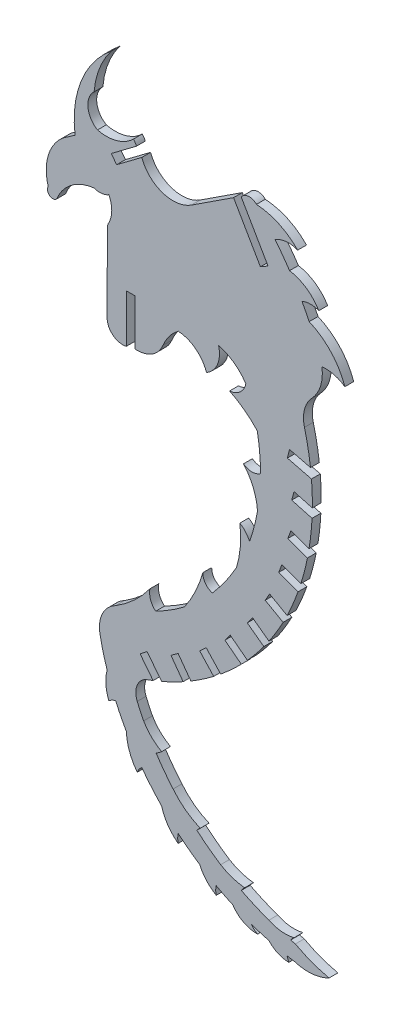
from build123d import *

# Parameters (mm, degrees)
BOSS_EXTRUDE1_DEPTH = 1.524


with BuildPart() as part:
    # Sketch1 → Boss-Extrude1 (new body)
    with BuildSketch(Plane.XY):
        with BuildLine():
            Line((-19.602484905, -30.40458867), (-17.182373841, -33.018427625))
            ThreePointArc((-17.182373841, -33.018427625), (-19.114471728, -34.403412724), (-21.120030481, -35.679704249))
            Line((-21.120030481, -35.679704249), (-23.318089916, -32.655808204))
            Line((-23.318089916, -32.655808204), (-24.551989159, -33.552918309))
            Line((-24.551989159, -33.552918309), (-22.451777673, -36.443937506))
            ThreePointArc((-22.451777673, -36.443937506), (-24.287296841, -37.398597732), (-26.166537799, -38.264022589))
            Line((-26.166537799, -38.264022589), (-28.67690709, -35.050088475))
            Line((-28.67690709, -35.050088475), (-29.879014549, -35.989918424))
            Line((-29.879014549, -35.989918424), (-27.633755498, -38.866035398))
            Line((-27.633755498, -38.866035398), (-28.929944275, -39.345306926))
            ThreePointArc((-28.929944275, -39.345306926), (-30.438413926, -41.060914268), (-30.37611387, -43.344531561))
            ThreePointArc((-30.37611387, -43.344531561), (-29.844797236, -44.539156878), (-29.273288892, -45.715084268))
            ThreePointArc((-29.273288892, -45.715084268), (-27.924618868, -47.442888916), (-26.166537799, -48.751846781))
            ThreePointArc((-26.166537799, -48.751846781), (-26.620268309, -49.124877395), (-27.129745176, -49.417206895))
            ThreePointArc((-27.129745176, -49.417206895), (-25.71988883, -51.425193975), (-24.185195687, -53.3394625))
            ThreePointArc((-24.185195687, -53.3394625), (-22.06528685, -55.395285651), (-19.507611608, -56.871334316))
            ThreePointArc((-19.507611608, -56.871334316), (-19.825662265, -57.136301645), (-20.087445304, -57.456978345))
            ThreePointArc((-20.087445304, -57.456978345), (-18.085947134, -59.072396881), (-15.98121565, -60.550800532))
            ThreePointArc((-15.98121565, -60.550800532), (-13.992971134, -61.479327702), (-11.846399806, -61.934860906))
            ThreePointArc((-11.846399806, -61.934860906), (-12.152170676, -62.259895124), (-12.422100483, -62.615255459))
            ThreePointArc((-12.422100483, -62.615255459), (-10.068181572, -63.719208102), (-7.645225941, -64.662039844))
            ThreePointArc((-7.645225941, -64.662039844), (-5.524325064, -65.2816944), (-3.319391114, -65.138660927))
            ThreePointArc((-3.319391114, -65.138660927), (-3.627748979, -65.435576398), (-3.899262019, -65.766520562))
            ThreePointArc((-3.899262019, -65.766520562), (-3.498948493, -65.860560168), (-3.097654962, -65.950325804))
            ThreePointArc((-3.097654962, -65.950325804), (-0.262873804, -67.244935383), (2.725203814, -68.130028787))
            ThreePointArc((2.725203814, -68.130028787), (-0.223324125, -68.977009903), (-3.2727907, -68.64242415))
            ThreePointArc((-3.2727907, -68.64242415), (-3.894035953, -68.5438652), (-4.513665711, -68.435613212))
            ThreePointArc((-4.513665711, -68.435613212), (-4.38771046, -68.856992068), (-4.205892413, -69.257450634))
            ThreePointArc((-4.205892413, -69.257450634), (-6.086864066, -68.859330249), (-7.645225834, -67.733247303))
            ThreePointArc((-7.645225834, -67.733247303), (-9.178691286, -67.291765398), (-10.693458736, -66.789866862))
            ThreePointArc((-10.693458736, -66.789866862), (-10.204080859, -67.331503597), (-9.59460317, -67.733247303))
            ThreePointArc((-9.59460317, -67.733247303), (-12.022729115, -67.178660923), (-13.872943452, -65.511307163))
            ThreePointArc((-13.872943452, -65.511307163), (-15.32207287, -64.820487366), (-16.742511873, -64.072449199))
            ThreePointArc((-16.742511873, -64.072449199), (-16.83298224, -64.791878181), (-16.742511873, -65.511307163))
            ThreePointArc((-16.742511873, -65.511307163), (-18.424401454, -64.14926984), (-19.602484905, -62.333776074))
            ThreePointArc((-19.602484905, -62.333776074), (-21.500743497, -60.988003895), (-23.318089916, -59.534821033))
            ThreePointArc((-23.318089916, -59.534821033), (-23.391769725, -60.287774776), (-23.318089916, -61.040728518))
            ThreePointArc((-23.318089916, -61.040728518), (-25.083741377, -59.189287964), (-26.166537799, -56.871334316))
            ThreePointArc((-26.166537799, -56.871334316), (-27.943176775, -54.916527573), (-29.587813978, -52.849432044))
            ThreePointArc((-29.587813978, -52.849432044), (-30.057930826, -53.336751691), (-30.37611387, -53.934455497))
            ThreePointArc((-30.37611387, -53.934455497), (-31.72023181, -51.488991265), (-32.263360174, -48.751846781))
            ThreePointArc((-32.263360174, -48.751846781), (-33.224295897, -46.960630757), (-34.093606765, -45.123200235))
            ThreePointArc((-34.093606765, -45.123200235), (-34.724295301, -45.333332251), (-35.26852772, -45.715084222))
            ThreePointArc((-35.26852772, -45.715084222), (-35.778431287, -43.508727905), (-35.573142184, -41.253541387))
            ThreePointArc((-35.573142184, -41.253541387), (-36.262207071, -38.884767803), (-36.804911157, -36.478241055))
            ThreePointArc((-36.804911157, -36.478241055), (-36.379187413, -33.235780646), (-34.093606765, -30.896782716))
            ThreePointArc((-34.093606765, -30.896782716), (-30.873720288, -28.447609442), (-28.183432172, -25.426273891))
            ThreePointArc((-28.183432172, -25.426273891), (-28.077817746, -26.989377804), (-27.18485716, -28.276649974))
            ThreePointArc((-27.18485716, -28.276649974), (-24.632848641, -26.822449292), (-22.219060199, -25.148808811))
            ThreePointArc((-22.219060199, -25.148808811), (-20.352965662, -21.922026938), (-19.043157097, -18.432208663))
            ThreePointArc((-19.043157097, -18.432208663), (-18.616398021, -19.838562637), (-17.400633216, -20.664317292))
            ThreePointArc((-17.400633216, -20.664317292), (-15.156999182, -17.818891426), (-13.236154755, -14.746319421))
            ThreePointArc((-13.236154755, -14.746319421), (-12.586187947, -11.330292244), (-12.664655577, -7.853865722))
            ThreePointArc((-12.664655577, -7.853865722), (-11.678390517, -8.675882943), (-10.999550853, -9.765657136))
            ThreePointArc((-10.999550853, -9.765657136), (-10.205411538, -7.19334204), (-9.621867643, -4.5652365))
            ThreePointArc((-9.621867643, -4.5652365), (-10.343001299, -1.421301186), (-12.033673017, 1.325695747))
            ThreePointArc((-12.033673017, 1.325695747), (-10.564897836, 0.839133584), (-9.096122655, 1.325695747))
            ThreePointArc((-9.096122655, 1.325695747), (-9.238337065, 4.398439349), (-9.663764364, 7.444911045))
            ThreePointArc((-9.663764364, 7.444911045), (-11.889027046, 9.445126668), (-14.439462627, 11.009714438))
            ThreePointArc((-14.439462627, 11.009714438), (-12.622320549, 11.776198112), (-11.639197468, 13.485868127))
            ThreePointArc((-11.639197468, 13.485868127), (-13.679495335, 15.613321564), (-16.345152823, 16.871551933))
            ThreePointArc((-16.345152823, 16.871551933), (-16.5083071, 13.966949207), (-18.41834042, 11.772613536))
            ThreePointArc((-18.41834042, 11.772613536), (-20.293185379, 14.376897698), (-23.294559088, 15.512281101))
            ThreePointArc((-23.294559088, 15.512281101), (-24.845480977, 13.979745117), (-25.932343938, 12.089572069))
            ThreePointArc((-25.932343938, 12.089572069), (-27.851371701, 9.818950969), (-30.7393246, 9.113177784))
            Line((-30.7393246, 9.113177784), (-30.739365801, 17.063759068))
            Line((-30.739365801, 17.063759068), (-32.263360174, 17.063759068))
            Line((-32.263360174, 17.063759068), (-32.263360174, 8.761268716))
            ThreePointArc((-32.263360174, 8.761268716), (-34.555343687, 9.269109006), (-35.573142184, 11.38457028))
            Line((-35.573142184, 11.38457028), (-35.527926853, 24.762214687))
            ThreePointArc((-35.527926853, 24.762214687), (-35.463572652, 25.273102917), (-35.26852772, 25.749659021))
            ThreePointArc((-35.26852772, 25.749659021), (-34.76819854, 27.834378756), (-35.26852772, 29.919098491))
            ThreePointArc((-35.26852772, 29.919098491), (-36.512710954, 29.485955181), (-37.820754807, 29.642882946))
            ThreePointArc((-37.820754807, 29.642882946), (-41.729979288, 28.095226002), (-44.292851433, 24.762214687))
            ThreePointArc((-44.292851433, 24.762214687), (-45.513428247, 24.680938121), (-45.729232446, 25.88503205))
            ThreePointArc((-45.729232446, 25.88503205), (-45.746623729, 30.530821656), (-43.205439397, 34.420043392))
            Line((-43.205439397, 34.420043392), (-41.098071776, 35.89971711))
            ThreePointArc((-41.098071776, 35.89971711), (-40.031539596, 44.562472245), (-34.850374923, 51.586456159))
            ThreePointArc((-34.850374923, 51.586456159), (-36.889272039, 48.013666537), (-37.820754807, 44.006888906))
            ThreePointArc((-37.820754807, 44.006888906), (-38.876801563, 41.163061153), (-37.234707854, 38.612351586))
            ThreePointArc((-37.234707854, 38.612351586), (-33.903641276, 38.676673562), (-31.024602142, 40.353359439))
            ThreePointArc((-31.024602142, 40.353359439), (-30.727463579, 39.97593433), (-30.50730984, 39.548999474))
            Line((-30.50730984, 39.548999474), (-34.850374923, 36.287545289))
            Line((-34.850374923, 36.287545289), (-33.934388939, 35.066561951))
            Line((-33.934388939, 35.066561951), (-29.590906246, 38.32814788))
            ThreePointArc((-29.590906246, 38.32814788), (-26.00393842, 34.837993903), (-21.040361546, 35.478632319))
            Line((-21.040361546, 35.478632319), (-13.754877133, 40.23562438))
            Line((-13.754877133, 40.23562438), (-9.121298801, 32.225216494))
            Line((-9.121298801, 32.225216494), (-7.801960889, 32.988207094))
            Line((-7.801960889, 32.988207094), (-12.433552393, 40.99861498))
            ThreePointArc((-12.433552393, 40.99861498), (-11.167432629, 41.720791341), (-9.802955112, 41.208152036))
            ThreePointArc((-9.802955112, 41.208152036), (-5.936656137, 40.237500091), (-2.694493928, 37.918272381))
            ThreePointArc((-2.694493928, 37.918272381), (-4.677929815, 38.219090922), (-6.566708996, 37.543056222))
            ThreePointArc((-6.566708996, 37.543056222), (-5.293674604, 35.8778749), (-4.09231636, 34.160265))
            ThreePointArc((-4.09231636, 34.160265), (-1.184466943, 32.989300759), (0.952741463, 30.696031101))
            ThreePointArc((0.952741463, 30.696031101), (-0.50482345, 30.961916762), (-1.954175494, 30.654395527))
            ThreePointArc((-1.954175494, 30.654395527), (-1.31039762, 29.454297412), (-0.699896059, 28.236934163))
            ThreePointArc((-0.699896059, 28.236934163), (3.077515896, 25.562161313), (5.454065658, 21.590352895))
            ThreePointArc((5.454065658, 21.590352895), (3.561132414, 22.456260476), (1.484832877, 22.604491527))
            ThreePointArc((1.484832877, 22.604491527), (1.262062582, 19.608548163), (-0.248272055, 17.011589841))
            ThreePointArc((-0.248272055, 17.011589841), (-1.52399282, 14.685708096), (-1.521843248, 12.032938837))
            ThreePointArc((-1.521843248, 12.032938837), (-0.911505152, 9.300940608), (-0.479904302, 6.535068661))
            Line((-0.479904302, 6.535068661), (-4.09231636, 7.444911045))
            Line((-4.09231636, 7.444911045), (-4.463877014, 5.965623344))
            Line((-4.463877014, 5.965623344), (-0.311141971, 4.919492018))
            ThreePointArc((-0.311141971, 4.919492018), (-0.184664396, 2.793264076), (-0.16344276, 0.663383449))
            Line((-0.16344276, 0.663383449), (-3.319391114, 1.52776024))
            Line((-3.319391114, 1.52776024), (-3.722743043, 0.055426943))
            Line((-3.722743043, 0.055426943), (-0.21378081, -0.904272298))
            ThreePointArc((-0.21378081, -0.904272298), (-0.404871254, -3.314288011), (-0.730863609, -5.709788017))
            Line((-0.730863609, -5.709788017), (-3.855869134, -4.5652365))
            Line((-3.855869134, -4.5652365), (-4.380425171, -5.998824116))
            Line((-4.380425171, -5.998824116), (-1.008562685, -7.233716773))
            ThreePointArc((-1.008562685, -7.233716773), (-1.519379645, -9.456694672), (-2.147145073, -11.649518258))
            Line((-2.147145073, -11.649518258), (-5.415628436, -10.427745988))
            Line((-5.415628436, -10.427745988), (-5.952105948, -11.856366535))
            Line((-5.952105948, -11.856366535), (-2.631905046, -13.09920701))
            ThreePointArc((-2.631905046, -13.09920701), (-3.509357984, -15.369765227), (-4.513665711, -17.587133997))
            Line((-4.513665711, -17.587133997), (-7.533721879, -15.867034763))
            Line((-7.533721879, -15.867034763), (-8.28876466, -17.19332708))
            Line((-8.28876466, -17.19332708), (-5.206998321, -18.946814274))
            ThreePointArc((-5.206998321, -18.946814274), (-6.370880972, -20.997449379), (-7.645225834, -22.981327484))
            Line((-7.645225834, -22.981327484), (-10.482362635, -20.895023282))
            Line((-10.482362635, -20.895023282), (-11.388413973, -22.123954946))
            Line((-11.388413973, -22.123954946), (-8.527199223, -24.229133501))
            ThreePointArc((-8.527199223, -24.229133501), (-9.902258982, -25.999935073), (-11.367588399, -27.69679607))
            Line((-11.367588399, -27.69679607), (-14.317185436, -25.426273891))
            Line((-14.317185436, -25.426273891), (-15.249067058, -26.634342341))
            Line((-15.249067058, -26.634342341), (-12.419643583, -28.814031506))
            ThreePointArc((-12.419643583, -28.814031506), (-14.154757291, -30.493012592), (-15.981215543, -32.07214125))
            Line((-15.981215543, -32.07214125), (-18.483829289, -29.368391991))
            Line((-18.483829289, -29.368391991), (-19.602484905, -30.40458867))
        make_face()
    extrude(amount=BOSS_EXTRUDE1_DEPTH)


solid = part.part
